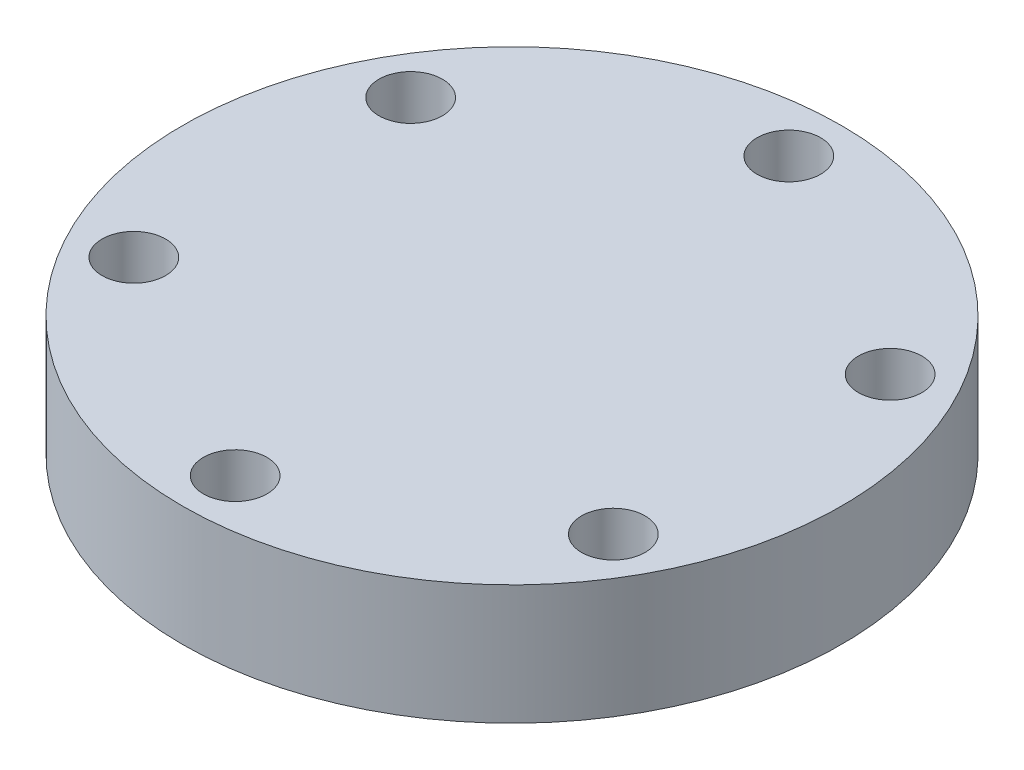
from build123d import *

# Parameters (mm, degrees)
SKETCH1_R          = 34.925
EXTRUDE1_DEPTH     = 12.7
SKETCH3_R          = 3.3655
CUT_EXTRUDE2_DEPTH = 12.7
CIRPATTERN1_COUNT  = 6


with BuildPart() as part:
    # Sketch1 → Extrude1 (new body)
    with BuildSketch(Plane(origin=(0, 0, 0), x_dir=(1, 0, 0), z_dir=(0, 1, 0))):
        Circle(SKETCH1_R)
    extrude(amount=EXTRUDE1_DEPTH)

    # Sketch3 → Cut-Extrude2 (cut)
    with BuildSketch(Plane(origin=(0, 0, 0), x_dir=(1, 0, 0), z_dir=(0, 1, 0))):
        with Locations((0, 29.337)):
            Circle(SKETCH3_R)
    cut_extrude2 = extrude(amount=CUT_EXTRUDE2_DEPTH, mode=Mode.SUBTRACT)

    # CirPattern1: Cut-Extrude2 ×6 about axis
    cirpattern1_axis = Axis((0, 0, 0), (0, 1, 0))
    for i in range(1, CIRPATTERN1_COUNT):
        add(cut_extrude2.rotate(cirpattern1_axis, i * 360 / CIRPATTERN1_COUNT), mode=Mode.SUBTRACT)


solid = part.part
